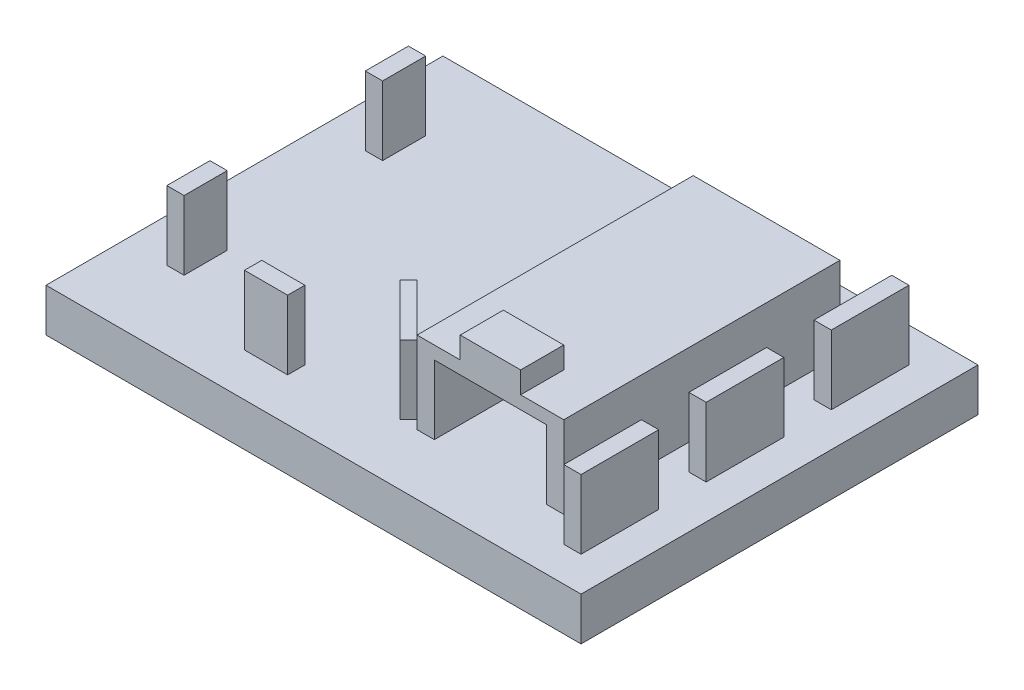
from build123d import *

# Parameters (mm, degrees)
SKETCH1_W           = 62
SKETCH1_H           = 46
BOSS_EXTRUDE1_DEPTH = 5
SKETCH2_W           = 2
SKETCH2_H           = 5
SKETCH2_H_2         = 9
SKETCH2_H_3         = 32
SKETCH2_W_2         = 5
SKETCH2_H_4         = 2
BOSS_EXTRUDE2_DEPTH = 8
SKETCH3_W           = 17
SKETCH3_H           = 32
BOSS_EXTRUDE3_DEPTH = 1.5
SKETCH4_W           = 7
SKETCH4_H           = 5
BOSS_EXTRUDE4_DEPTH = 2.5


with BuildPart() as part:
    # Sketch1 → Boss-Extrude1 (new body)
    with BuildSketch(Plane(origin=(0, 0, 0), x_dir=(1, 0, 0), z_dir=(0, 1, 0))):
        with Locations((4.368421053, -7.717105263)):
            Rectangle(SKETCH1_W, SKETCH1_H)
    extrude(amount=BOSS_EXTRUDE1_DEPTH)

    # Sketch2 → Boss-Extrude2 (add)
    with BuildSketch(Plane(origin=(0, 5, 0), x_dir=(1, 0, 0), z_dir=(0, 1, 0))):
        with Locations((-20.631578947, 3.782894737)):
            Rectangle(SKETCH2_W, SKETCH2_H)
        with Locations((-20.631578947, -19.217105263)):
            Rectangle(SKETCH2_W, SKETCH2_H)
        Polygon((7.368421053, -23.717105263), (8.368421053, -22.717105263), (2.368421053, -16.717105263), (1.368421053, -17.717105263), align=None)
        with Locations((30.368421053, 6.782894737)):
            Rectangle(SKETCH2_W, SKETCH2_H_2)
        with Locations((30.368421053, -7.717105263)):
            Rectangle(SKETCH2_W, SKETCH2_H_2)
        with Locations((30.368421053, -22.217105263)):
            Rectangle(SKETCH2_W, SKETCH2_H_2)
        with Locations((10.368421053, -7.717105263)):
            Rectangle(SKETCH2_W, SKETCH2_H_3)
        with Locations((25.368421053, -7.717105263)):
            Rectangle(SKETCH2_W, SKETCH2_H_3)
        with Locations((-6.131578947, -24.717105263)):
            Rectangle(SKETCH2_W_2, SKETCH2_H_4)
    extrude(amount=BOSS_EXTRUDE2_DEPTH)

    # Sketch3 → Boss-Extrude3 (add)
    with BuildSketch(Plane(origin=(0, 13, 0), x_dir=(1, 0, 0), z_dir=(0, 1, 0))):
        with Locations((17.868421053, -7.717105263)):
            Rectangle(SKETCH3_W, SKETCH3_H)
    extrude(amount=BOSS_EXTRUDE3_DEPTH)

    # Sketch4 → Boss-Extrude4 (add)
    with BuildSketch(Plane(origin=(0, 14.5, 0), x_dir=(1, 0, 0), z_dir=(0, 1, 0))):
        with Locations((17.868421053, -21.217105263)):
            Rectangle(SKETCH4_W, SKETCH4_H)
    extrude(amount=BOSS_EXTRUDE4_DEPTH)


solid = part.part
